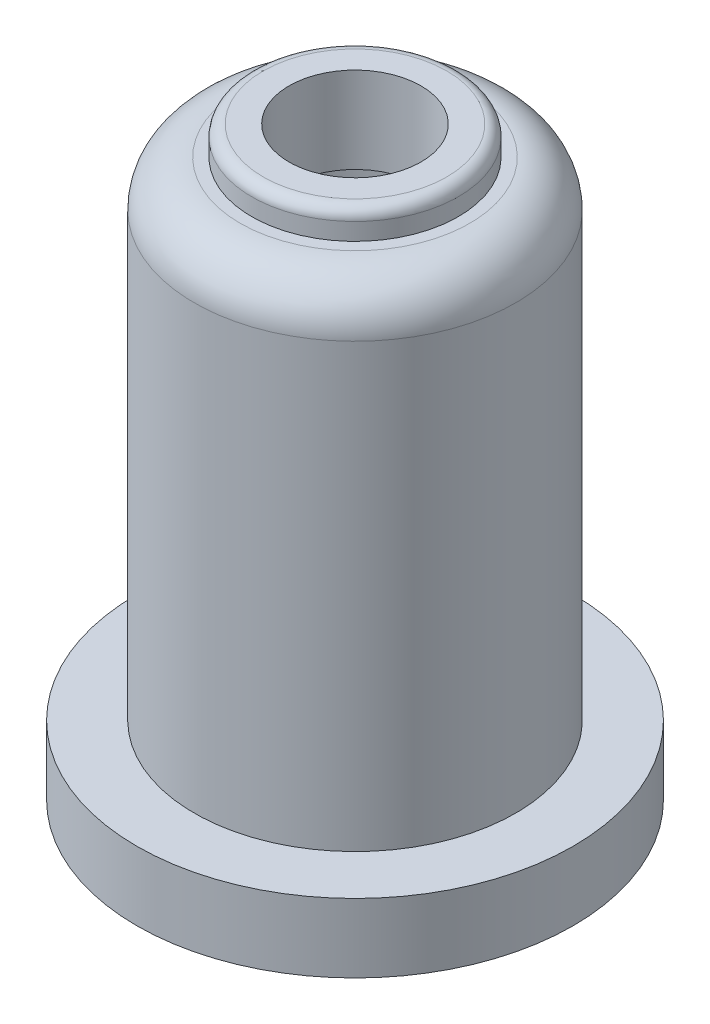
from build123d import *


with BuildPart() as part:
    # Çizim1 → Döndür1 (revolve)
    with BuildSketch(Plane.XY):
        with BuildLine():
            Line((38, 0), (38, 12))
            Line((38, 12), (28, 12))
            Line((28, 12), (28, 89))
            ThreePointArc((28, 89), (25.656854249, 94.656854249), (20, 97))
            Line((20, 97), (18, 97))
            Line((18, 97), (18, 100))
            ThreePointArc((18, 100), (17.414213562, 101.414213562), (16, 102))
            Line((16, 102), (11.5, 102))
            Line((11.5, 102), (11.5, 87))
            Line((11.5, 87), (20, 87))
            ThreePointArc((20, 87), (21.414213562, 86.414213562), (22, 85))
            Line((22, 85), (22, 43))
            ThreePointArc((22, 43), (21.414213562, 41.585786438), (20, 41))
            Line((20, 41), (6, 41))
            Line((6, 41), (6, 31))
            Line((6, 31), (20, 31))
            ThreePointArc((20, 31), (21.414213562, 30.414213562), (22, 29))
            Line((22, 29), (22, 3))
            Line((22, 3), (35, 3))
            Line((35, 3), (35, 0))
            Line((35, 0), (38, 0))
        make_face()
    revolve(axis=Axis((0, 0, 0), (0, 1, 0)))


solid = part.part
